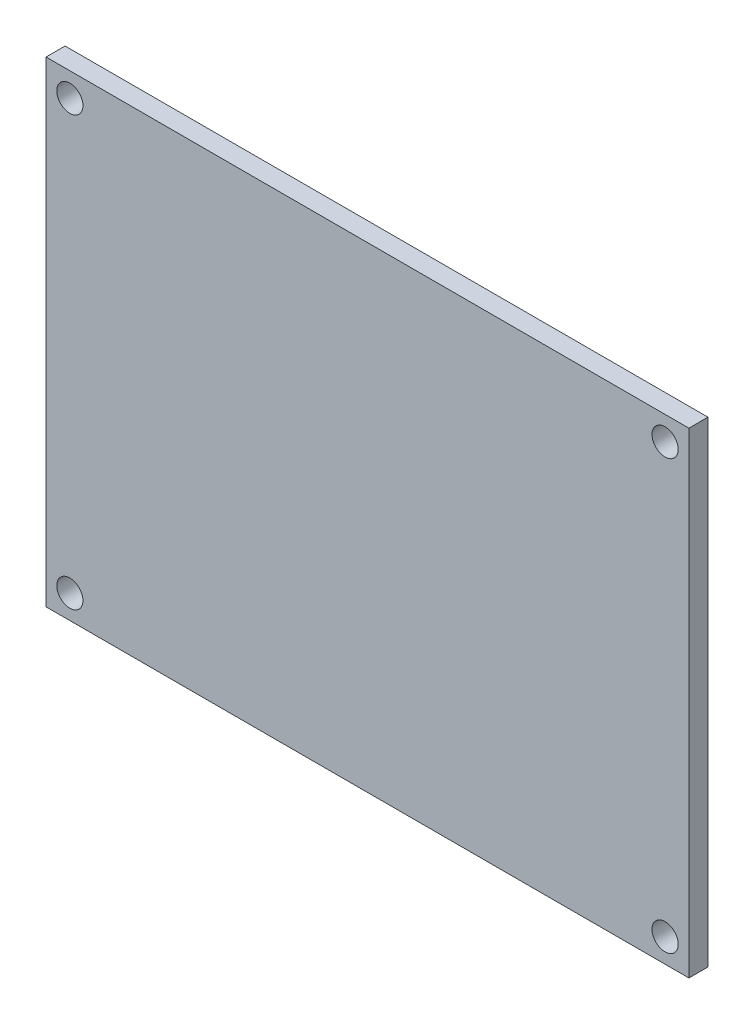
from build123d import *

# Parameters (mm, degrees)
MODEL_W         = 54
MODEL_H         = 40
MODEL_R         = 1.1
EXTRUDE_1_DEPTH = 1.6


with BuildPart() as part:
    # Model → ﾎﾞｽ - 押し出し1 (new body)
    with BuildSketch(Plane.XY):
        with Locations((27, 20)):
            Rectangle(MODEL_W, MODEL_H)
        with Locations((2, 2)):
            Circle(MODEL_R, mode=Mode.SUBTRACT)
        with Locations((52, 2)):
            Circle(MODEL_R, mode=Mode.SUBTRACT)
        with Locations((52, 38)):
            Circle(MODEL_R, mode=Mode.SUBTRACT)
        with Locations((2, 38)):
            Circle(MODEL_R, mode=Mode.SUBTRACT)
    extrude(amount=EXTRUDE_1_DEPTH)


solid = part.part
